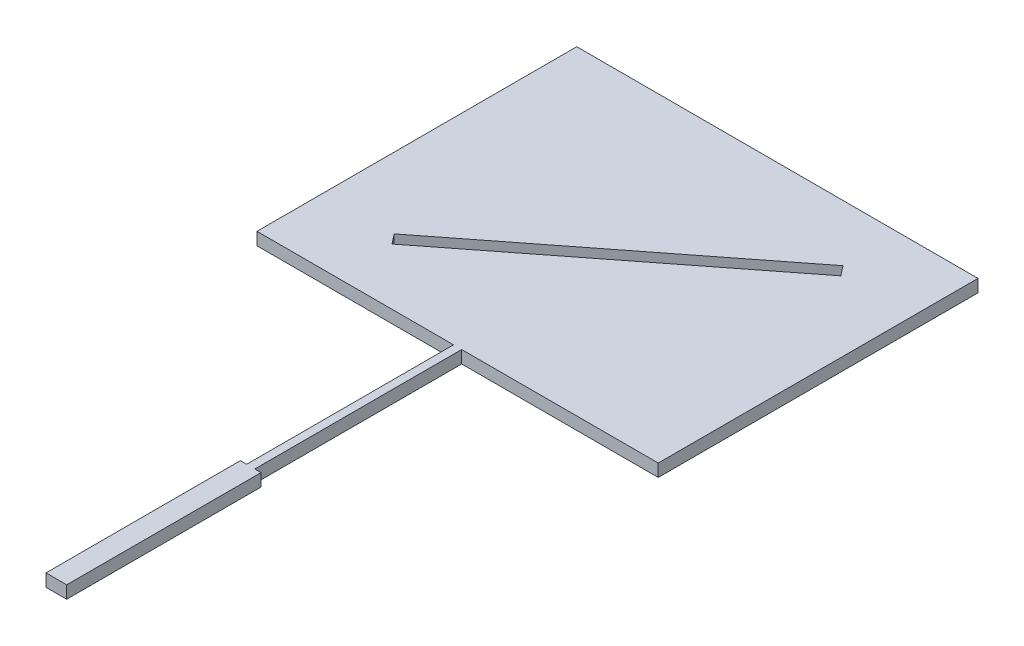
from build123d import *

# Parameters (mm, degrees)
BOSS_EXTRUDE1_DEPTH = 2
CUT_EXTRUDE1_DEPTH  = 3


with BuildPart() as part:
    # Sketch1 → Boss-Extrude1 (new body)
    with BuildSketch(Plane(origin=(0, 0, 0), x_dir=(1, 0, 0), z_dir=(0, 1, 0))):
        Polygon((0, 0), (3.3, 0), (3.3, 31), (2.3, 31), (2.3, 64), (33.65, 64), (33.65, 115), (-30.35, 115), (-30.35, 64), (1, 64), (1, 31), (0, 31), align=None)
    extrude(amount=BOSS_EXTRUDE1_DEPTH)

    # Sketch2 → Cut-Extrude1 (cut, through all)
    with BuildSketch(Plane(origin=(0, 2, 0), x_dir=(1, 0, 0), z_dir=(0, 1, 0))):
        Polygon((21.744274217, 105.199367621), (22.359935692, 104.411356867), (-17.828612742, 73.012621626), (-19.059935692, 74.588643133), (21.128612742, 105.987378374), align=None)
    extrude(amount=-CUT_EXTRUDE1_DEPTH, mode=Mode.SUBTRACT)


solid = part.part
